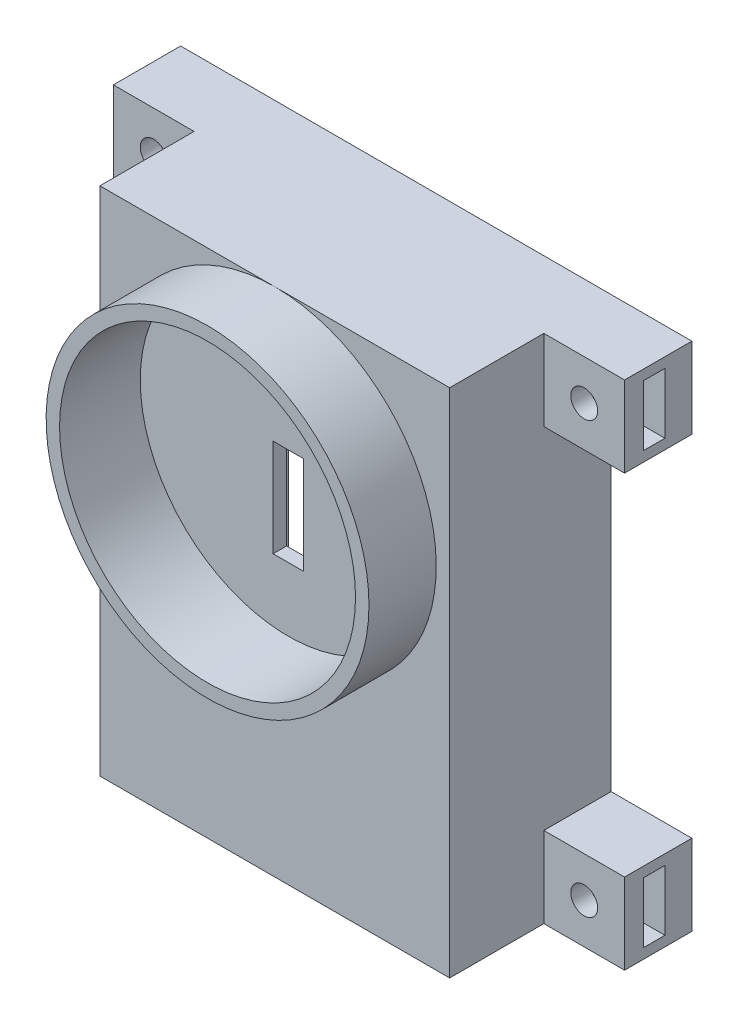
from build123d import *

# Parameters (mm, degrees)
SKETCH_1_W          = 26
SKETCH_1_H          = 38
EXTRUDE_1_DEPTH     = 12
SKETCH_2_W          = 22
SKETCH_2_H          = 34
CUT_EXTRUDE_1_DEPTH = 10
SKETCH_3_W          = 2.25
SKETCH_3_H          = 7.25
CUT_EXTRUDE_3_DEPTH = 12
SKETCH_4_W          = 6
SKETCH_4_H          = 6
EXTRUDE_2_DEPTH     = 5
SKETCH_5_R          = 1
CUT_EXTRUDE_4_DEPTH = 13
CUT_EXTRUDE_START   = 2
CUT_EXTRUDE_5_DEPTH = 1.6
SKETCH_7_R          = 12
SKETCH_7_R_2        = 11
EXTRUDE_3_DEPTH     = 5
SKETCH_9_R          = 11
CUT_EXTRUDE_7_DEPTH = 1
SKETCH_10_W         = 14.41096837
SKETCH_10_H         = 3
EXTRUDE_4_DEPTH     = 2
CUT_EXTRUDE_START_2 = 20
SKETCH_11_W         = 1.6
SKETCH_11_H         = 4.5
CUT_EXTRUDE_8_DEPTH = 4
CUT_EXTRUDE_START_3 = -20
SKETCH_13_W         = 1.6
SKETCH_13_H         = 4.5
CUT_EXTRUDE_9_DEPTH = 4


with BuildPart() as part:
    # ｽｹｯﾁ1 → ﾎﾞｽ - 押し出し1 (new body)
    with BuildSketch(Plane.XY):
        Rectangle(SKETCH_1_W, SKETCH_1_H)
    extrude(amount=EXTRUDE_1_DEPTH)

    # ｽｹｯﾁ2 → ｶｯﾄ - 押し出し1 (cut)
    with BuildSketch(Plane.XY):
        Rectangle(SKETCH_2_W, SKETCH_2_H)
    extrude(amount=CUT_EXTRUDE_1_DEPTH, mode=Mode.SUBTRACT)

    # ｽｹｯﾁ3 → ｶｯﾄ - 押し出し3 (cut)
    with BuildSketch(Plane.XY):
        with Locations((0, 4.375)):
            Rectangle(SKETCH_3_W, SKETCH_3_H)
    extrude(amount=CUT_EXTRUDE_3_DEPTH, mode=Mode.SUBTRACT)

    # ｽｹｯﾁ4 → ﾎﾞｽ - 押し出し2 (add)
    with BuildSketch(Plane.XY):
        with Locations((16, 16)):
            Rectangle(SKETCH_4_W, SKETCH_4_H)
        with Locations((16, -16)):
            Rectangle(SKETCH_4_W, SKETCH_4_H)
        with Locations((-16, -16)):
            Rectangle(SKETCH_4_W, SKETCH_4_H)
        with Locations((-16, 16)):
            Rectangle(SKETCH_4_W, SKETCH_4_H)
    extrude(amount=EXTRUDE_2_DEPTH)

    # ｽｹｯﾁ5 → ｶｯﾄ - 押し出し4 (cut, through all)
    with BuildSketch(Plane.XY):
        with Locations((-16, 16)):
            Circle(SKETCH_5_R)
        with Locations((-16, -16)):
            Circle(SKETCH_5_R)
        with Locations((16, -16)):
            Circle(SKETCH_5_R)
        with Locations((16, 16)):
            Circle(SKETCH_5_R)
    extrude(amount=CUT_EXTRUDE_4_DEPTH, mode=Mode.SUBTRACT)

    # ｽｹｯﾁ6 → ｶｯﾄ - 押し出し5 (cut)
    with BuildSketch(Plane.XY.offset(CUT_EXTRUDE_START)):
        Polygon((-17.184124892, 17.98272075), (-18.309148984, 15.965878137), (-17.125024092, 13.983157387), (-14.815875108, 14.01727925), (-13.690851016, 16.034121863), (-14.874975908, 18.016842613), align=None)
        Polygon((-17.07560545, -13.956374239), (-18.307634549, -15.909688764), (-17.2320291, -17.953314524), (-14.92439455, -18.043625761), (-13.692365451, -16.090311236), (-14.7679709, -14.046685476), align=None)
        Polygon((14.939341307, 18.051423035), (13.693086191, 16.107154145), (14.753744884, 14.055731109), (17.060658693, 13.948576965), (18.306913809, 15.892845855), (17.246255116, 17.944268891), align=None)
        Polygon((14.854466591, -13.994735294), (13.690623119, -15.98942868), (14.836156527, -17.994693386), (17.145533409, -18.005264706), (18.309376881, -16.01057132), (17.163843473, -14.005306614), align=None)
    extrude(amount=CUT_EXTRUDE_5_DEPTH, mode=Mode.SUBTRACT)

    # ｽｹｯﾁ7 → ﾎﾞｽ - 押し出し3 (add)
    with BuildSketch(Plane.XY.offset(12)):
        with Locations((0, 7)):
            Circle(SKETCH_7_R)
        with Locations((0, 7)):
            Circle(SKETCH_7_R_2, mode=Mode.SUBTRACT)
    extrude(amount=EXTRUDE_3_DEPTH)

    # ｽｹｯﾁ9 → ｶｯﾄ - 押し出し7 (cut)
    with BuildSketch(Plane.XY.offset(12)):
        with Locations((0, 7)):
            Circle(SKETCH_9_R)
    extrude(amount=-CUT_EXTRUDE_7_DEPTH, mode=Mode.SUBTRACT)

    # ｽｹｯﾁ10 → ﾎﾞｽ - 押し出し4 (add)
    with BuildSketch(Plane.XY.offset(10)):
        with Locations((0, -11.5)):
            Rectangle(SKETCH_10_W, SKETCH_10_H)
    extrude(amount=-EXTRUDE_4_DEPTH)

    # ｽｹｯﾁ11 → ｶｯﾄ - 押し出し8 (cut)
    with BuildSketch(Plane(origin=(0, 0, 0), x_dir=(0, 0, -1), z_dir=(1, 0, 0)).offset(CUT_EXTRUDE_START_2)):
        with Locations((-2.8, 16)):
            Rectangle(SKETCH_11_W, SKETCH_11_H)
        with Locations((-2.8, -16)):
            Rectangle(SKETCH_11_W, SKETCH_11_H)
    extrude(amount=-CUT_EXTRUDE_8_DEPTH, mode=Mode.SUBTRACT)

    # ｽｹｯﾁ13 → ｶｯﾄ - 押し出し9 (cut)
    with BuildSketch(Plane(origin=(0, 0, 0), x_dir=(0, 0, -1), z_dir=(1, 0, 0)).offset(CUT_EXTRUDE_START_3)):
        with Locations((-2.8, 16)):
            Rectangle(SKETCH_13_W, SKETCH_13_H)
        with Locations((-2.8, -16)):
            Rectangle(SKETCH_13_W, SKETCH_13_H)
    extrude(amount=CUT_EXTRUDE_9_DEPTH, mode=Mode.SUBTRACT)


solid = part.part
